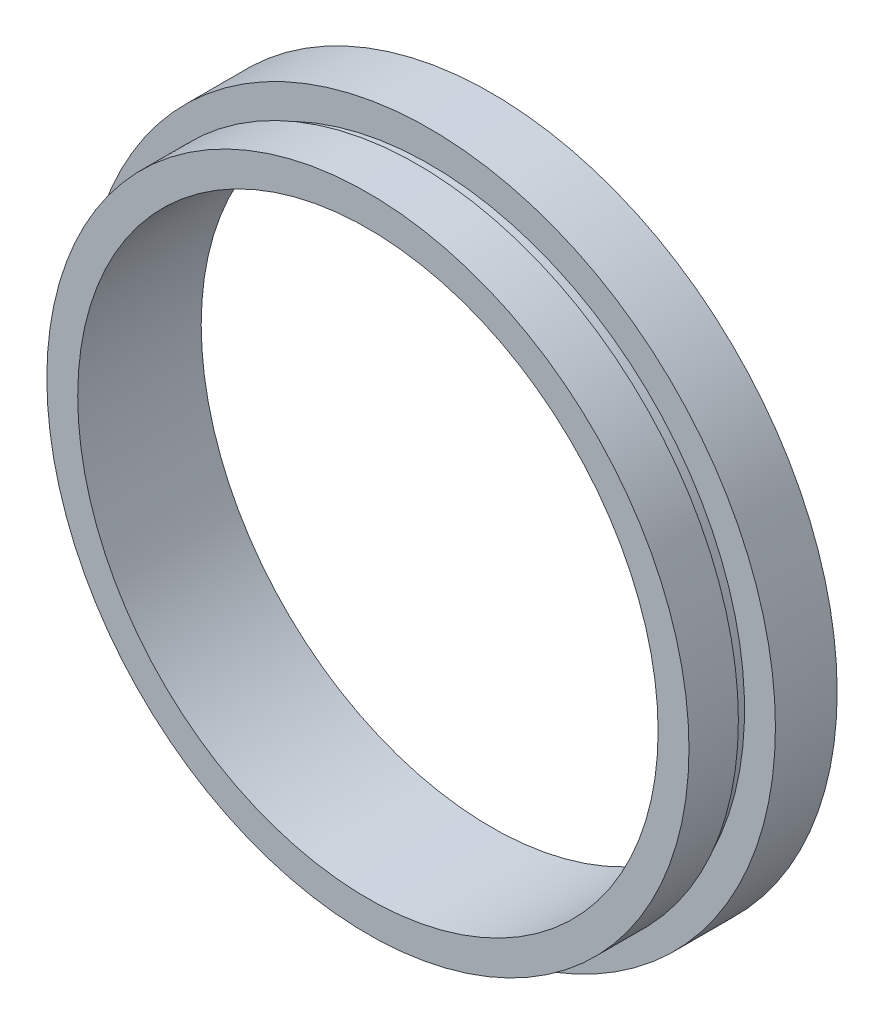
from build123d import *


with BuildPart() as part:
    # 草图1 → 旋转1 (revolve)
    with BuildSketch(Plane(origin=(0, 0, 0), x_dir=(1, 0, 0), z_dir=(0, 1, 0)), mode=Mode.PRIVATE) as revolve_1_sk:
        Polygon((23.5, 0), (23.5, 10), (28, 10), (28, 5), (25.5, 5), (25.5, 4), (26, 4), (26, 0), align=None)
    revolve(revolve_1_sk.sketch.rotate(Axis((0, 0, -19.14057971), (0, 0, 1)), 180), axis=Axis((0, 0, -19.14057971), (0, 0, 1)))  # turned: the seam where the file's is


solid = part.part
